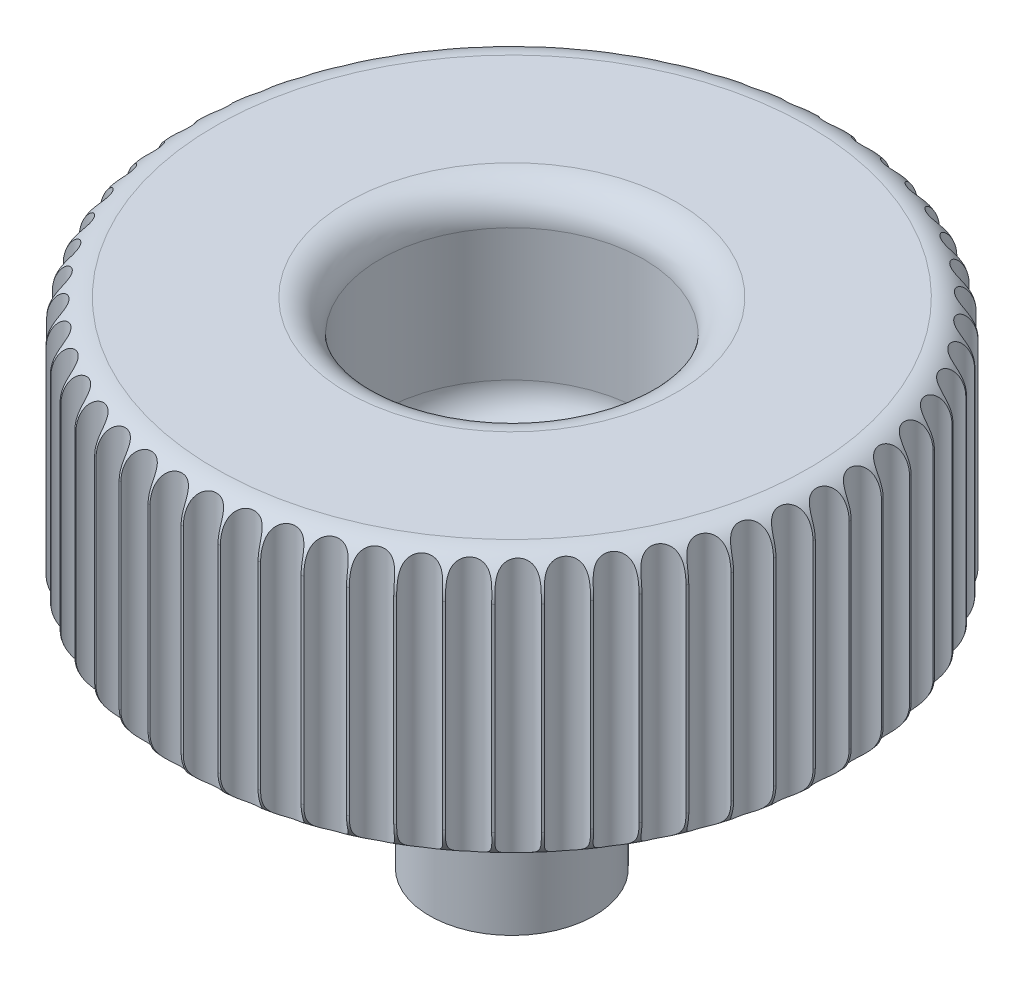
from build123d import *

# Parameters (mm, degrees)
SKETCH2_R           = 2.5
BOSS_EXTRUDE1_DEPTH = 7
SKETCH3_R           = 0.5
CUT_EXTRUDE1_DEPTH  = 12


with BuildPart() as part:
    # Sketch1 → Revolve1 (revolve)
    with BuildSketch(Plane(origin=(0, 0, 0), x_dir=(0, 0, -1), z_dir=(1, 0, 0))):
        with BuildLine():
            Line((0, 0), (0, 2))
            Line((0, 2), (3, 2))
            ThreePointArc((3, 2), (3.707106781, 2.292893219), (4, 3))
            Line((4, 3), (4, 7))
            ThreePointArc((4, 7), (4.292893219, 7.707106781), (5, 8))
            Line((5, 8), (9, 8))
            ThreePointArc((9, 8), (9.707106781, 7.707106781), (10, 7))
            Line((10, 7), (10, 1))
            ThreePointArc((10, 1), (9.707106781, 0.292893219), (9, 0))
            Line((9, 0), (8, 0))
            Line((8, 0), (8, 5.294117647))
            ThreePointArc((8, 5.294117647), (7.707106781, 6.001224428), (7, 6.294117647))
            Line((7, 6.294117647), (6, 6.294117647))
            ThreePointArc((6, 6.294117647), (5.292893219, 6.001224428), (5, 5.294117647))
            Line((5, 5.294117647), (5, 1))
            ThreePointArc((5, 1), (4.707106781, 0.292893219), (4, 0))
            Line((4, 0), (0, 0))
        make_face()
    revolve(axis=Axis((0, 0, 0), (0, 1, 0)))

    # Sketch2 → Boss-Extrude1 (add)
    with BuildSketch(Plane.XZ):
        Circle(SKETCH2_R)
    extrude(amount=BOSS_EXTRUDE1_DEPTH)

    # Sketch3 → Cut-Extrude1 (cut)
    with BuildSketch(Plane(origin=(0, 0, 0), x_dir=(1, 0, 0), z_dir=(0, 1, 0))):
        with Locations((0, 10)):
            Circle(SKETCH3_R)
        with Locations((1.062934856, 9.943348002)):
            Circle(SKETCH3_R)
        with Locations((2.113826236, 9.774033898)):
            Circle(SKETCH3_R)
        with Locations((3.14076712, 9.493976085)):
            Circle(SKETCH3_R)
        with Locations((4.132121858, 9.106347729)):
            Circle(SKETCH3_R)
        with Locations((5.076658003, 8.615540814)):
            Circle(SKETCH3_R)
        with Locations((5.963673585, 8.027116379)):
            Circle(SKETCH3_R)
        with Locations((6.783118363, 7.347741509)):
            Circle(SKETCH3_R)
        with Locations((7.525707699, 6.585113791)):
            Circle(SKETCH3_R)
        with Locations((8.183027759, 5.747874102)):
            Circle(SKETCH3_R)
        with Locations((8.747630845, 4.845508703)):
            Circle(SKETCH3_R)
        with Locations((9.213119779, 3.888241755)):
            Circle(SKETCH3_R)
        with Locations((9.574220384, 2.886919473)):
            Circle(SKETCH3_R)
        with Locations((9.826841246, 1.852887241)):
            Circle(SKETCH3_R)
        with Locations((9.96812007, 0.797861056)):
            Circle(SKETCH3_R)
        with Locations((9.996456111, -0.266205214)):
            Circle(SKETCH3_R)
        with Locations((9.91152831, -1.327255273)):
            Circle(SKETCH3_R)
        with Locations((9.714298933, -2.373266999)):
            Circle(SKETCH3_R)
        with Locations((9.407002667, -3.392388661)):
            Circle(SKETCH3_R)
        with Locations((8.993121302, -4.373073205)):
            Circle(SKETCH3_R)
        with Locations((8.477344279, -5.304209081)):
            Circle(SKETCH3_R)
        with Locations((7.865515558, -6.175246149)):
            Circle(SKETCH3_R)
        with Locations((7.164567403, -6.976315211)):
            Circle(SKETCH3_R)
        with Locations((6.382441836, -7.698339834)):
            Circle(SKETCH3_R)
        with Locations((5.528000654, -8.333139191)):
            Circle(SKETCH3_R)
        with Locations((4.610925014, -8.873520751)):
            Circle(SKETCH3_R)
        with Locations((3.641605753, -9.313361775)):
            Circle(SKETCH3_R)
        with Locations((2.631025642, -9.647678688)):
            Circle(SKETCH3_R)
        with Locations((1.59063496, -9.872683547)):
            Circle(SKETCH3_R)
        with Locations((0.532221748, -9.985826957)):
            Circle(SKETCH3_R)
        with Locations((-0.532221748, -9.985826957)):
            Circle(SKETCH3_R)
        with Locations((-1.59063496, -9.872683547)):
            Circle(SKETCH3_R)
        with Locations((-2.631025642, -9.647678688)):
            Circle(SKETCH3_R)
        with Locations((-3.641605753, -9.313361775)):
            Circle(SKETCH3_R)
        with Locations((-4.610925014, -8.873520751)):
            Circle(SKETCH3_R)
        with Locations((-5.528000654, -8.333139191)):
            Circle(SKETCH3_R)
        with Locations((-6.382441836, -7.698339834)):
            Circle(SKETCH3_R)
        with Locations((-7.164567403, -6.976315211)):
            Circle(SKETCH3_R)
        with Locations((-7.865515558, -6.175246149)):
            Circle(SKETCH3_R)
        with Locations((-8.477344279, -5.304209081)):
            Circle(SKETCH3_R)
        with Locations((-8.993121302, -4.373073205)):
            Circle(SKETCH3_R)
        with Locations((-9.407002667, -3.392388661)):
            Circle(SKETCH3_R)
        with Locations((-9.714298933, -2.373266999)):
            Circle(SKETCH3_R)
        with Locations((-9.91152831, -1.327255273)):
            Circle(SKETCH3_R)
        with Locations((-9.996456111, -0.266205214)):
            Circle(SKETCH3_R)
        with Locations((-9.96812007, 0.797861056)):
            Circle(SKETCH3_R)
        with Locations((-9.826841246, 1.852887241)):
            Circle(SKETCH3_R)
        with Locations((-9.574220384, 2.886919473)):
            Circle(SKETCH3_R)
        with Locations((-9.213119779, 3.888241755)):
            Circle(SKETCH3_R)
        with Locations((-8.747630845, 4.845508703)):
            Circle(SKETCH3_R)
        with Locations((-8.183027759, 5.747874102)):
            Circle(SKETCH3_R)
        with Locations((-7.525707699, 6.585113791)):
            Circle(SKETCH3_R)
        with Locations((-6.783118363, 7.347741509)):
            Circle(SKETCH3_R)
        with Locations((-5.963673585, 8.027116379)):
            Circle(SKETCH3_R)
        with Locations((-5.076658003, 8.615540814)):
            Circle(SKETCH3_R)
        with Locations((-4.132121858, 9.106347729)):
            Circle(SKETCH3_R)
        with Locations((-3.14076712, 9.493976085)):
            Circle(SKETCH3_R)
        with Locations((-2.113826236, 9.774033898)):
            Circle(SKETCH3_R)
        with Locations((-1.062934856, 9.943348002)):
            Circle(SKETCH3_R)
    extrude(amount=CUT_EXTRUDE1_DEPTH, mode=Mode.SUBTRACT)


solid = part.part
